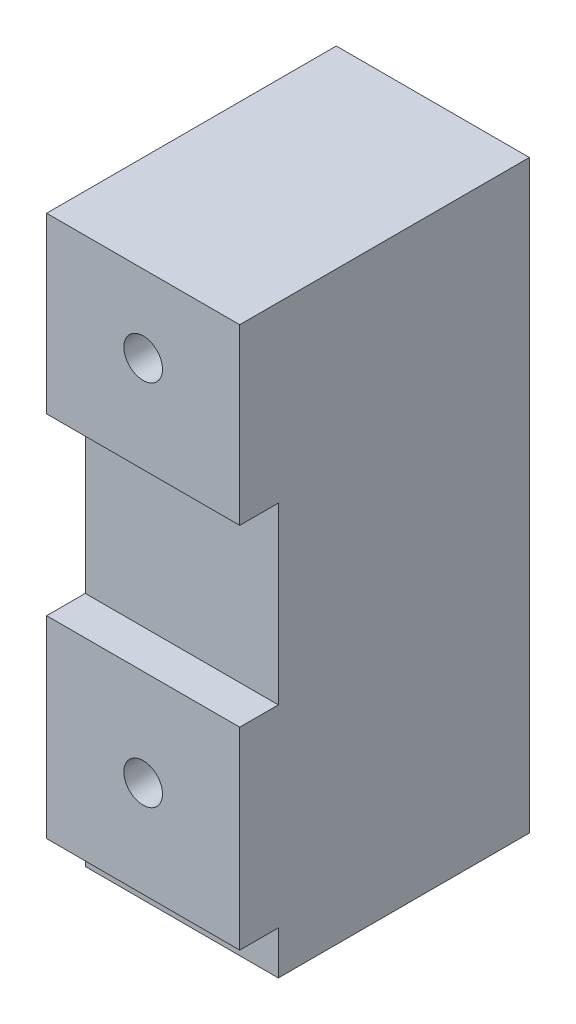
from build123d import *

# Parameters (mm, degrees)
SKETCH1_W           = 10
SKETCH1_H           = 27.05
SKETCH1_R           = 1
SKETCH1_H_2         = 3.25
BOSS_EXTRUDE1_DEPTH = 15
SKETCH2_OUTSIDE_W   = 19.052
SKETCH2_OUTSIDE_H   = 39.352
SKETCH2_OUTSIDE_W_2 = 10
SKETCH2_OUTSIDE_H_2 = 10
CUT_EXTRUDE1_DEPTH  = 2


with BuildPart() as part:
    # Sketch1 → Boss-Extrude1 (new body)
    with BuildSketch(Plane.XY):
        with Locations((0, 9.525)):
            Rectangle(SKETCH1_W, SKETCH1_H)
        with Locations((0, 19.05)):
            Circle(SKETCH1_R, mode=Mode.SUBTRACT)
        Circle(SKETCH1_R, mode=Mode.SUBTRACT)
        with Locations((0, -5.625)):
            Rectangle(SKETCH1_W, SKETCH1_H_2)
    extrude(amount=-BOSS_EXTRUDE1_DEPTH)

    # Sketch2 outside → Cut-Extrude1 (cut)
    with BuildSketch(Plane.XY):
        with Locations((0, 7.9)):
            Rectangle(SKETCH2_OUTSIDE_W, SKETCH2_OUTSIDE_H)
        with Locations((0, 19.05)):
            Rectangle(SKETCH2_OUTSIDE_W_2, SKETCH2_OUTSIDE_H_2, mode=Mode.SUBTRACT)
        Rectangle(SKETCH2_OUTSIDE_W_2, SKETCH2_OUTSIDE_H_2, mode=Mode.SUBTRACT)
    extrude(amount=-CUT_EXTRUDE1_DEPTH, mode=Mode.SUBTRACT)


solid = part.part
